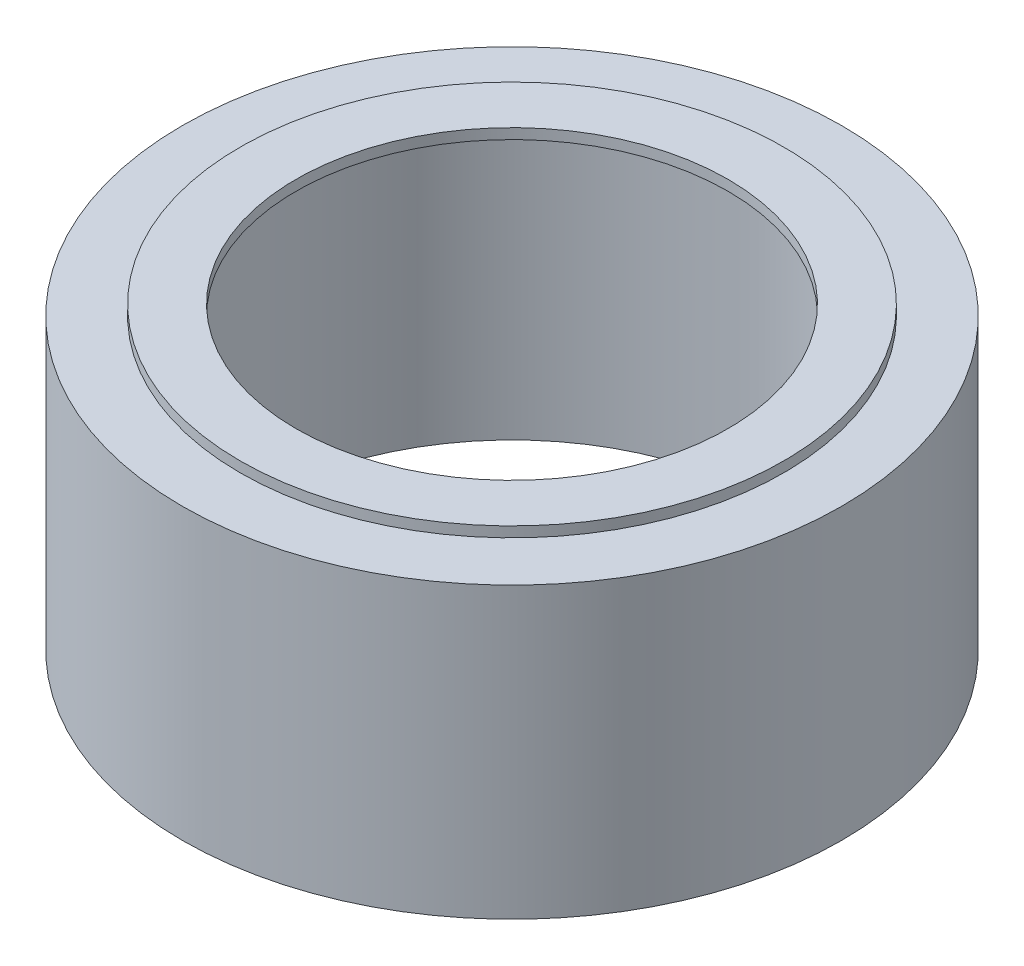
from build123d import *

# Parameters (mm, degrees)
SKETCH2_R           = 15.95
SKETCH2_R_2         = 12.45
BOSS_EXTRUDE1_DEPTH = 14
SKETCH3_R           = 13.15
SKETCH3_R_2         = 12.45
SKETCH3_R_3         = 10.45
BOSS_EXTRUDE2_DEPTH = 0.5


with BuildPart() as part:
    # Sketch2 → Boss-Extrude1 (new body)
    with BuildSketch(Plane(origin=(0, 0, 0), x_dir=(1, 0, 0), z_dir=(0, 1, 0))):
        with Locations(Location((0, 0, 0), (0, 0, 270))):
            Circle(SKETCH2_R)
        with Locations(Location((0, 0, 0), (0, 0, 270))):
            Circle(SKETCH2_R_2, mode=Mode.SUBTRACT)
    extrude(amount=BOSS_EXTRUDE1_DEPTH)


with BuildPart() as body_2:
    # Sketch3 → Boss-Extrude2 (new body)
    with BuildSketch(Plane(origin=(0, 14, 0), x_dir=(1, 0, 0), z_dir=(0, 1, 0))):
        with Locations(Location((0, 0, 0), (0, 0, 270))):
            Circle(SKETCH3_R)
        with Locations(Location((0, 0, 0), (0, 0, 270))):
            Circle(SKETCH3_R_2, mode=Mode.SUBTRACT)
        with Locations(Location((0, 0, 0), (0, 0, 270))):
            Circle(SKETCH3_R_2)
        with Locations(Location((0, 0, 0), (0, 0, 270))):
            Circle(SKETCH3_R_3, mode=Mode.SUBTRACT)
    extrude(amount=BOSS_EXTRUDE2_DEPTH)


solid = Compound([part.part, body_2.part])
